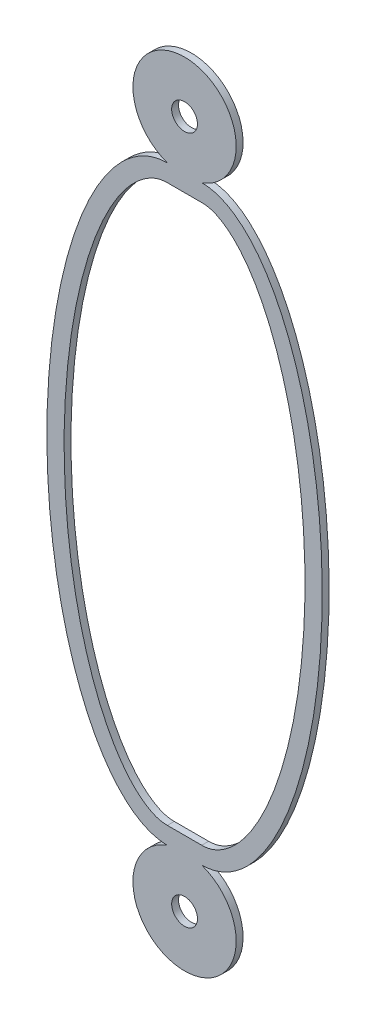
from build123d import *

# Parameters (mm, degrees)
SKETCH1_R           = 0.375
BOSS_EXTRUDE1_DEPTH = 0.1


with BuildPart() as part:
    # Sketch1 → Boss-Extrude1 (new body, symmetric)
    with BuildSketch(Plane.XY):
        with BuildLine():
            ThreePointArc((0.5, 8.585786438), (0, 11.5), (-0.5, 8.585786438))
            add(Edge.make_bspline(
                [(-0.5, 8.585786438), (-4, 8.585786438), (-4, 0), (-4, -8.585786438), (-0.5, -8.585786438)],
                knots=[0, 0, 0, 1.570796327, 1.570796327, 3.141592654, 3.141592654, 3.141592654], degree=2, weights=[1, 0.707106781, 1, 0.707106781, 1]))
            ThreePointArc((-0.5, -8.585786438), (0, -11.5), (0.5, -8.585786438))
            add(Edge.make_bspline(
                [(0.5, -8.585786438), (4, -8.585786438), (4, 0), (4, 8.585786438), (0.5, 8.585786438)],
                knots=[3.141592654, 3.141592654, 3.141592654, 4.71238898, 4.71238898, 6.283185307, 6.283185307, 6.283185307], degree=2, weights=[1, 0.707106781, 1, 0.707106781, 1]))
        make_face()
        with Locations((0, 10)):
            Circle(SKETCH1_R, mode=Mode.SUBTRACT)
        with Locations((0, -10)):
            Circle(SKETCH1_R, mode=Mode.SUBTRACT)
        with BuildLine():
            Line((-0.5, 8.085786438), (0.5, 8.085786438))
            add(Edge.make_bspline(
                [(0.5, 8.085786438), (0.659147926, 8.085786438), (0.945909937, 8.018367263), (1.481906813, 7.635759744), (2.024622706, 6.927674691), (2.692554099, 5.589462007), (3.321902915, 3.29131119), (3.589048543, 0), (3.321902915, -3.29131119), (2.692554099, -5.589462007), (2.024622706, -6.927674691), (1.481906813, -7.635759744), (0.945909937, -8.018367263), (0.659147926, -8.085786438), (0.5, -8.085786438)],
                knots=[-3.141592654, -3.141592654, -3.141592654, -3.141592654, -2.945243113, -2.748893572, -2.552544031, -2.35619449, -1.963495408, -1.570796327, -1.178097245, -0.785398163, -0.589048623, -0.392699082, -0.196349541, 0, 0, 0, 0], degree=3))
            Line((0.5, -8.085786438), (-0.5, -8.085786438))
            add(Edge.make_bspline(
                [(-0.5, 8.085786438), (-0.659147926, 8.085786438), (-0.945909937, 8.018367263), (-1.481906813, 7.635759744), (-2.024622706, 6.927674691), (-2.692554099, 5.589462007), (-3.321902915, 3.29131119), (-3.589048543, 0), (-3.321902915, -3.29131119), (-2.692554099, -5.589462007), (-2.024622706, -6.927674691), (-1.481906813, -7.635759744), (-0.945909937, -8.018367263), (-0.659147926, -8.085786438), (-0.5, -8.085786438)],
                knots=[0, 0, 0, 0, 0.196349541, 0.392699082, 0.589048623, 0.785398163, 1.178097245, 1.570796327, 1.963495408, 2.35619449, 2.552544031, 2.748893572, 2.945243113, 3.141592654, 3.141592654, 3.141592654, 3.141592654], degree=3))
        make_face(mode=Mode.SUBTRACT)
    extrude(amount=BOSS_EXTRUDE1_DEPTH, both=True)


solid = part.part
